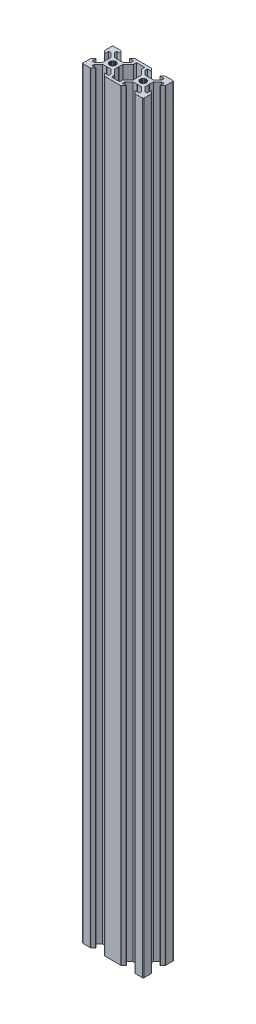
from build123d import *

# Parameters (mm, degrees)
SALIENTE_EXTRUIR1_DEPTH = 500


with BuildPart() as part:
    # Croquis1 → Saliente-Extruir1 (new body)
    with BuildSketch(Plane(origin=(0, 0, 0), x_dir=(1, 0, 0), z_dir=(0, 1, 0))):
        with BuildLine():
            Line((665.699676498, 63.423080772), (665.699676729, 66.055446415))
            Line((665.699676729, 66.055446415), (665.492702209, 66.26242093))
            Line((665.492702209, 66.26242093), (665.699676723, 66.46939545))
            Line((665.699676723, 66.46939545), (665.699676583, 69.101760426))
            Line((665.699676583, 69.101760426), (668.360336793, 71.762420557))
            Line((668.360336793, 71.762420557), (669.999676621, 71.762420533))
            Line((669.999676621, 71.762420533), (669.999676677, 69.149047891))
            Line((669.999676677, 69.149047891), (670.106303574, 69.149047891))
            Line((670.106303574, 69.149047891), (671.621875558, 70.664619875))
            Line((671.621875558, 70.664619875), (671.649030782, 70.693613213))
            Line((671.649030782, 70.693613213), (671.67423161, 70.72432051))
            Line((671.67423161, 70.72432051), (671.697370127, 70.756610274))
            Line((671.697370127, 70.756610274), (671.718347251, 70.790344234))
            Line((671.718347251, 70.790344234), (671.737073155, 70.825377936))
            Line((671.737073155, 70.825377936), (671.753467652, 70.861561362))
            Line((671.753467652, 70.861561362), (671.767460537, 70.898739567))
            Line((671.767460537, 70.898739567), (671.778991891, 70.93675335))
            Line((671.778991891, 70.93675335), (671.788012336, 70.975439928))
            Line((671.788012336, 70.975439928), (671.794483244, 71.014633642))
            Line((671.794483244, 71.014633642), (671.798376905, 71.054166656))
            Line((671.798376905, 71.054166656), (671.799676647, 71.093869684))
            Line((671.799676647, 71.093869684), (671.799676665, 74.762420505))
            Line((671.799676665, 74.762420505), (671.799676665, 75.762420526))
            ThreePointArc((671.799676665, 75.762420526), (671.653230055, 76.115973917), (671.299676665, 76.262420526))
            Line((671.299676665, 76.262420526), (670.299676688, 76.262420526))
            Line((670.299676688, 76.262420526), (666.631125347, 76.262421015))
            Line((666.631125347, 76.262421015), (666.591422318, 76.261121273))
            Line((666.591422318, 76.261121273), (666.551889304, 76.257227611))
            Line((666.551889304, 76.257227611), (666.512695591, 76.250756703))
            Line((666.512695591, 76.250756703), (666.474009012, 76.241736259))
            Line((666.474009012, 76.241736259), (666.43599523, 76.230204904))
            Line((666.43599523, 76.230204904), (666.398817024, 76.216212019))
            Line((666.398817024, 76.216212019), (666.362633599, 76.199817522))
            Line((666.362633599, 76.199817522), (666.327599896, 76.181091618))
            Line((666.327599896, 76.181091618), (666.293865936, 76.160114494))
            Line((666.293865936, 76.160114494), (666.261576173, 76.136975977))
            Line((666.261576173, 76.136975977), (666.230868875, 76.11177515))
            Line((666.230868875, 76.11177515), (666.201875538, 76.084619926))
            Line((666.201875538, 76.084619926), (664.686303553, 74.569047941))
            Line((664.686303553, 74.569047941), (664.686303553, 74.462421044))
            Line((664.686303553, 74.462421044), (667.299676662, 74.462420572))
            Line((667.299676662, 74.462420572), (667.299676638, 72.823080744))
            Line((667.299676638, 72.823080744), (664.639016427, 70.162420613))
            Line((664.639016427, 70.162420613), (661.999544628, 70.162420653))
            Line((661.999544628, 70.162420653), (661.799676597, 69.962552628))
            Line((661.799676597, 69.962552628), (661.599808573, 70.162420659))
            Line((661.599808573, 70.162420659), (658.960336773, 70.162420698))
            Line((658.960336773, 70.162420698), (656.299676642, 72.823080908))
            Line((656.299676642, 72.823080908), (656.299676667, 74.462420736))
            Line((656.299676667, 74.462420736), (658.913049712, 74.462420898))
            Line((658.913049712, 74.462420898), (658.913049712, 74.569047795))
            Line((658.913049712, 74.569047795), (657.397477727, 76.08461978))
            Line((657.397477727, 76.08461978), (657.36848439, 76.111775004))
            Line((657.36848439, 76.111775004), (657.337777093, 76.136975831))
            Line((657.337777093, 76.136975831), (657.305487329, 76.160114348))
            Line((657.305487329, 76.160114348), (657.271753369, 76.181091472))
            Line((657.271753369, 76.181091472), (657.236719667, 76.199817376))
            Line((657.236719667, 76.199817376), (657.200536241, 76.216211873))
            Line((657.200536241, 76.216211873), (657.163358036, 76.230204758))
            Line((657.163358036, 76.230204758), (657.125344253, 76.241736113))
            Line((657.125344253, 76.241736113), (657.086657674, 76.250756557))
            Line((657.086657674, 76.250756557), (657.047463961, 76.257227465))
            Line((657.047463961, 76.257227465), (657.007930947, 76.261121127))
            Line((657.007930947, 76.261121127), (656.899676693, 76.262420672))
            Line((656.899676693, 76.262420672), (646.699676644, 76.262420878))
            Line((646.699676644, 76.262420878), (646.591422331, 76.261121207))
            Line((646.591422331, 76.261121207), (646.551889317, 76.257227546))
            Line((646.551889317, 76.257227546), (646.512695604, 76.250756638))
            Line((646.512695604, 76.250756638), (646.474009025, 76.241736193))
            Line((646.474009025, 76.241736193), (646.435995243, 76.230204839))
            Line((646.435995243, 76.230204839), (646.398817037, 76.216211953))
            Line((646.398817037, 76.216211953), (646.362633612, 76.199817457))
            Line((646.362633612, 76.199817457), (646.327599909, 76.181091553))
            Line((646.327599909, 76.181091553), (646.293865949, 76.160114429))
            Line((646.293865949, 76.160114429), (646.261576186, 76.136975911))
            Line((646.261576186, 76.136975911), (646.230868888, 76.111775084))
            Line((646.230868888, 76.111775084), (646.201875551, 76.08461986))
            Line((646.201875551, 76.08461986), (644.686303566, 74.569047876))
            Line((644.686303566, 74.569047876), (644.686303566, 74.462420979))
            Line((644.686303566, 74.462420979), (647.29967667, 74.46242087))
            Line((647.29967667, 74.46242087), (647.299676646, 72.823081042))
            Line((647.299676646, 72.823081042), (644.639016435, 70.162420911))
            Line((644.639016435, 70.162420911), (641.999544636, 70.162420951))
            Line((641.999544636, 70.162420951), (641.799676605, 69.962552926))
            Line((641.799676605, 69.962552926), (641.599808581, 70.162420957))
            Line((641.599808581, 70.162420957), (638.960336781, 70.162420996))
            Line((638.960336781, 70.162420996), (636.29967665, 72.823081206))
            Line((636.29967665, 72.823081206), (636.299676675, 74.462421034))
            Line((636.299676675, 74.462421034), (638.913049725, 74.462421125))
            Line((638.913049725, 74.462421125), (638.913049725, 74.569048022))
            Line((638.913049725, 74.569048022), (637.39747774, 76.084620006))
            Line((637.39747774, 76.084620006), (637.368484403, 76.11177523))
            Line((637.368484403, 76.11177523), (637.337777106, 76.136976058))
            Line((637.337777106, 76.136976058), (637.305487342, 76.160114575))
            Line((637.305487342, 76.160114575), (637.271753382, 76.181091699))
            Line((637.271753382, 76.181091699), (637.23671968, 76.199817603))
            Line((637.23671968, 76.199817603), (637.200536254, 76.216212099))
            Line((637.200536254, 76.216212099), (637.163358049, 76.230204985))
            Line((637.163358049, 76.230204985), (637.125344266, 76.241736339))
            Line((637.125344266, 76.241736339), (637.086657687, 76.250756784))
            Line((637.086657687, 76.250756784), (637.047463974, 76.257227692))
            Line((637.047463974, 76.257227692), (637.00793096, 76.261121353))
            Line((637.00793096, 76.261121353), (636.968227932, 76.262421095))
            Line((636.968227932, 76.262421095), (633.299676703, 76.262421078))
            Line((633.299676703, 76.262421078), (632.299676681, 76.262421078))
            ThreePointArc((632.299676681, 76.262421078), (631.946123291, 76.115974468), (631.799676681, 75.762421078))
            Line((631.799676681, 75.762421078), (631.799676681, 74.762421101))
            Line((631.799676681, 74.762421101), (631.799676631, 71.093869765))
            Line((631.799676631, 71.093869765), (631.800976373, 71.054166736))
            Line((631.800976373, 71.054166736), (631.804870035, 71.014633722))
            Line((631.804870035, 71.014633722), (631.811340942, 70.975440009))
            Line((631.811340942, 70.975440009), (631.820361387, 70.93675343))
            Line((631.820361387, 70.93675343), (631.831892741, 70.898739648))
            Line((631.831892741, 70.898739648), (631.845885627, 70.861561442))
            Line((631.845885627, 70.861561442), (631.862280123, 70.825378017))
            Line((631.862280123, 70.825378017), (631.881006027, 70.790344314))
            Line((631.881006027, 70.790344314), (631.901983151, 70.756610354))
            Line((631.901983151, 70.756610354), (631.925121669, 70.724320591))
            Line((631.925121669, 70.724320591), (631.950322496, 70.693613293))
            Line((631.950322496, 70.693613293), (631.97747772, 70.664619956))
            Line((631.97747772, 70.664619956), (633.493049704, 69.149047971))
            Line((633.493049704, 69.149047971), (633.599676601, 69.149047971))
            Line((633.599676601, 69.149047971), (633.599676636, 71.762421075))
            Line((633.599676636, 71.762421075), (635.239016463, 71.762421051))
            Line((635.239016463, 71.762421051), (637.899676594, 69.10176084))
            Line((637.899676594, 69.10176084), (637.899676555, 66.469395531))
            Line((637.899676555, 66.469395531), (638.106651069, 66.26242101))
            Line((638.106651069, 66.26242101), (637.899676549, 66.055446496))
            Line((637.899676549, 66.055446496), (637.89967651, 63.423081186))
            Line((637.89967651, 63.423081186), (635.239016299, 60.762421055))
            Line((635.239016299, 60.762421055), (633.599676472, 60.76242108))
            Line((633.599676472, 60.76242108), (633.599676455, 63.37579413))
            Line((633.599676455, 63.37579413), (633.493049558, 63.37579413))
            Line((633.493049558, 63.37579413), (631.977477574, 61.860222145))
            Line((631.977477574, 61.860222145), (631.95032235, 61.831228808))
            Line((631.95032235, 61.831228808), (631.925121523, 61.800521511))
            Line((631.925121523, 61.800521511), (631.901983005, 61.768231747))
            Line((631.901983005, 61.768231747), (631.881005881, 61.734497787))
            Line((631.881005881, 61.734497787), (631.862279977, 61.699464085))
            Line((631.862279977, 61.699464085), (631.845885481, 61.663280659))
            Line((631.845885481, 61.663280659), (631.831892595, 61.626102454))
            Line((631.831892595, 61.626102454), (631.820361241, 61.588088671))
            Line((631.820361241, 61.588088671), (631.811340796, 61.549402092))
            Line((631.811340796, 61.549402092), (631.804869888, 61.510208379))
            Line((631.804869888, 61.510208379), (631.800976227, 61.470675365))
            Line((631.800976227, 61.470675365), (631.799676485, 61.430972337))
            Line((631.799676485, 61.430972337), (631.799676428, 57.762421108))
            Line((631.799676428, 57.762421108), (631.799676428, 56.762421086))
            ThreePointArc((631.799676428, 56.762421086), (631.946123034, 56.408867689), (632.299676428, 56.262421073))
            Line((632.299676428, 56.262421073), (633.299676405, 56.262421086))
            Line((633.299676405, 56.262421086), (636.899676457, 56.262421032))
            Line((636.899676457, 56.262421032), (637.007930844, 56.263720778))
            Line((637.007930844, 56.263720778), (637.047463858, 56.267614439))
            Line((637.047463858, 56.267614439), (637.086657571, 56.274085347))
            Line((637.086657571, 56.274085347), (637.12534415, 56.283105792))
            Line((637.12534415, 56.283105792), (637.163357932, 56.294637146))
            Line((637.163357932, 56.294637146), (637.200536138, 56.308630032))
            Line((637.200536138, 56.308630032), (637.236719563, 56.325024528))
            Line((637.236719563, 56.325024528), (637.271753266, 56.343750432))
            Line((637.271753266, 56.343750432), (637.305487226, 56.364727556))
            Line((637.305487226, 56.364727556), (637.33777699, 56.387866074))
            Line((637.33777699, 56.387866074), (637.368484287, 56.413066901))
            Line((637.368484287, 56.413066901), (637.397477624, 56.440222125))
            Line((637.397477624, 56.440222125), (638.913049609, 57.955794109))
            Line((638.913049609, 57.955794109), (638.913049609, 58.062421006))
            Line((638.913049609, 58.062421006), (636.29967643, 58.062421041))
            Line((636.29967643, 58.062421041), (636.299676455, 59.701760868))
            Line((636.299676455, 59.701760868), (638.960336665, 62.362420999))
            Line((638.960336665, 62.362420999), (641.599808465, 62.36242096))
            Line((641.599808465, 62.36242096), (641.799676495, 62.562288985))
            Line((641.799676495, 62.562288985), (641.99954452, 62.362420954))
            Line((641.99954452, 62.362420954), (644.639016319, 62.362420915))
            Line((644.639016319, 62.362420915), (647.29967645, 59.701760704))
            Line((647.29967645, 59.701760704), (647.299676426, 58.062420877))
            Line((647.299676426, 58.062420877), (644.68630345, 58.06242086))
            Line((644.68630345, 58.06242086), (644.68630345, 57.955793963))
            Line((644.68630345, 57.955793963), (646.201875435, 56.440221979))
            Line((646.201875435, 56.440221979), (646.230868772, 56.413066755))
            Line((646.230868772, 56.413066755), (646.261576069, 56.387865928))
            Line((646.261576069, 56.387865928), (646.293865833, 56.36472741))
            Line((646.293865833, 56.36472741), (646.327599793, 56.343750286))
            Line((646.327599793, 56.343750286), (646.362633495, 56.325024382))
            Line((646.362633495, 56.325024382), (646.398816921, 56.308629886))
            Line((646.398816921, 56.308629886), (646.435995126, 56.294637))
            Line((646.435995126, 56.294637), (646.474008909, 56.283105646))
            Line((646.474008909, 56.283105646), (646.512695488, 56.274085201))
            Line((646.512695488, 56.274085201), (646.551889201, 56.267614293))
            Line((646.551889201, 56.267614293), (646.591422215, 56.263720632))
            Line((646.591422215, 56.263720632), (646.699676453, 56.262420886))
            Line((646.699676453, 56.262420886), (656.899676884, 56.262420681))
            Line((656.899676884, 56.262420681), (657.007931063, 56.263720551))
            Line((657.007931063, 56.263720551), (657.047464077, 56.267614213))
            Line((657.047464077, 56.267614213), (657.086657791, 56.274085121))
            Line((657.086657791, 56.274085121), (657.125344369, 56.283105565))
            Line((657.125344369, 56.283105565), (657.163358152, 56.29463692))
            Line((657.163358152, 56.29463692), (657.200536357, 56.308629805))
            Line((657.200536357, 56.308629805), (657.236719783, 56.325024302))
            Line((657.236719783, 56.325024302), (657.271753485, 56.343750206))
            Line((657.271753485, 56.343750206), (657.305487445, 56.36472733))
            Line((657.305487445, 56.36472733), (657.337777209, 56.387865847))
            Line((657.337777209, 56.387865847), (657.368484506, 56.413066674))
            Line((657.368484506, 56.413066674), (657.397477844, 56.440221898))
            Line((657.397477844, 56.440221898), (658.913049828, 57.955793883))
            Line((658.913049828, 57.955793883), (658.913049828, 58.06242078))
            Line((658.913049828, 58.06242078), (656.299676422, 58.062420743))
            Line((656.299676422, 58.062420743), (656.299676447, 59.70176057))
            Line((656.299676447, 59.70176057), (658.960336657, 62.362420701))
            Line((658.960336657, 62.362420701), (661.599808456, 62.362420662))
            Line((661.599808456, 62.362420662), (661.799676487, 62.562288686))
            Line((661.799676487, 62.562288686), (661.999544512, 62.362420656))
            Line((661.999544512, 62.362420656), (664.639016311, 62.362420617))
            Line((664.639016311, 62.362420617), (667.299676442, 59.701760406))
            Line((667.299676442, 59.701760406), (667.299676418, 58.062420579))
            Line((667.299676418, 58.062420579), (664.68630367, 58.062420926))
            Line((664.68630367, 58.062420926), (664.68630367, 57.955794029))
            Line((664.68630367, 57.955794029), (666.201875654, 56.440222044))
            Line((666.201875654, 56.440222044), (666.230868992, 56.41306682))
            Line((666.230868992, 56.41306682), (666.261576289, 56.387865993))
            Line((666.261576289, 56.387865993), (666.293866052, 56.364727476))
            Line((666.293866052, 56.364727476), (666.327600012, 56.343750352))
            Line((666.327600012, 56.343750352), (666.362633715, 56.325024448))
            Line((666.362633715, 56.325024448), (666.39881714, 56.308629951))
            Line((666.39881714, 56.308629951), (666.435995346, 56.294637066))
            Line((666.435995346, 56.294637066), (666.474009128, 56.283105711))
            Line((666.474009128, 56.283105711), (666.512695707, 56.274085267))
            Line((666.512695707, 56.274085267), (666.55188942, 56.267614359))
            Line((666.55188942, 56.267614359), (666.591422434, 56.263720697))
            Line((666.591422434, 56.263720697), (666.69967688, 56.262420827))
            Line((666.69967688, 56.262420827), (670.29967639, 56.262420535))
            Line((670.29967639, 56.262420535), (671.299676411, 56.262420535))
            ThreePointArc((671.299676411, 56.262420535), (671.653229809, 56.408867141), (671.799676425, 56.762420535))
            Line((671.799676425, 56.762420535), (671.799676411, 57.762420512))
            Line((671.799676411, 57.762420512), (671.799676793, 61.430972256))
            Line((671.799676793, 61.430972256), (671.798377051, 61.470675285))
            Line((671.798377051, 61.470675285), (671.79448339, 61.510208299))
            Line((671.79448339, 61.510208299), (671.788012482, 61.549402012))
            Line((671.788012482, 61.549402012), (671.778992037, 61.588088591))
            Line((671.778992037, 61.588088591), (671.767460683, 61.626102373))
            Line((671.767460683, 61.626102373), (671.753467798, 61.663280579))
            Line((671.753467798, 61.663280579), (671.737073301, 61.699464004))
            Line((671.737073301, 61.699464004), (671.718347397, 61.734497707))
            Line((671.718347397, 61.734497707), (671.697370273, 61.768231667))
            Line((671.697370273, 61.768231667), (671.674231756, 61.80052143))
            Line((671.674231756, 61.80052143), (671.649030928, 61.831228727))
            Line((671.649030928, 61.831228727), (671.621875704, 61.860222065))
            Line((671.621875704, 61.860222065), (670.10630372, 63.375794049))
            Line((670.10630372, 63.375794049), (669.999676823, 63.375794049))
            Line((669.999676823, 63.375794049), (669.999676457, 60.762420537))
            Line((669.999676457, 60.762420537), (668.360336629, 60.762420562))
            Line((668.360336629, 60.762420562), (665.699676498, 63.423080772))
        make_face()
        Polygon((657.899676727, 66.469395334), (657.899676586, 69.101760542), (654.499676638, 72.501760592), (654.499676667, 74.462420763), (649.099676669, 74.462420843), (649.09967664, 72.501760672), (645.699676591, 69.101760724), (645.699676552, 66.469395415), (645.492702031, 66.2624209), (645.699676546, 66.05544638), (645.699676506, 63.42308107), (649.099676454, 60.023081021), (649.099676425, 58.06242085), (654.499676423, 58.062420769), (654.499676452, 60.02308094), (657.899676501, 63.423080888), (657.899676541, 66.057651509), (658.10444575, 66.262420712), align=None, mode=Mode.SUBTRACT)
        Polygon((639.98102324, 65.212420993), (640.314752347, 64.777496752), (640.749676588, 64.443767645), (641.256156593, 64.233976757), (641.799676588, 64.162420993), (642.343196582, 64.233976757), (642.849676588, 64.443767645), (643.284600828, 64.777496752), (643.618329936, 65.212420993), (643.828120823, 65.718900998), (643.899676588, 66.262420993), (643.828120823, 66.805940987), (643.618329936, 67.312420993), (643.284600828, 67.747345233), (642.849676588, 68.08107434), (642.343196582, 68.290865228), (641.799676588, 68.362420993), (641.256156593, 68.290865228), (640.749676588, 68.08107434), (640.314752347, 67.747345233), (639.98102324, 67.312420993), (639.771232352, 66.805940987), (639.699676588, 66.262420993), (639.771232352, 65.718900998), align=None, mode=Mode.SUBTRACT)
        Polygon((659.981023231, 65.212420993), (660.314752339, 64.777496752), (660.749676579, 64.443767645), (661.256156585, 64.233976757), (661.799676579, 64.162420993), (662.343196574, 64.233976757), (662.849676579, 64.443767645), (663.28460082, 64.777496752), (663.618329927, 65.212420993), (663.828120815, 65.718900998), (663.899676579, 66.262420993), (663.828120815, 66.805940987), (663.618329927, 67.312420993), (663.28460082, 67.747345233), (662.849676579, 68.08107434), (662.343196574, 68.290865228), (661.799676579, 68.362420993), (661.256156585, 68.290865228), (660.749676579, 68.08107434), (660.314752339, 67.747345233), (659.981023231, 67.312420993), (659.771232344, 66.805940987), (659.699676579, 66.262420993), (659.771232344, 65.718900998), align=None, mode=Mode.SUBTRACT)
    extrude(amount=SALIENTE_EXTRUIR1_DEPTH)


solid = part.part
